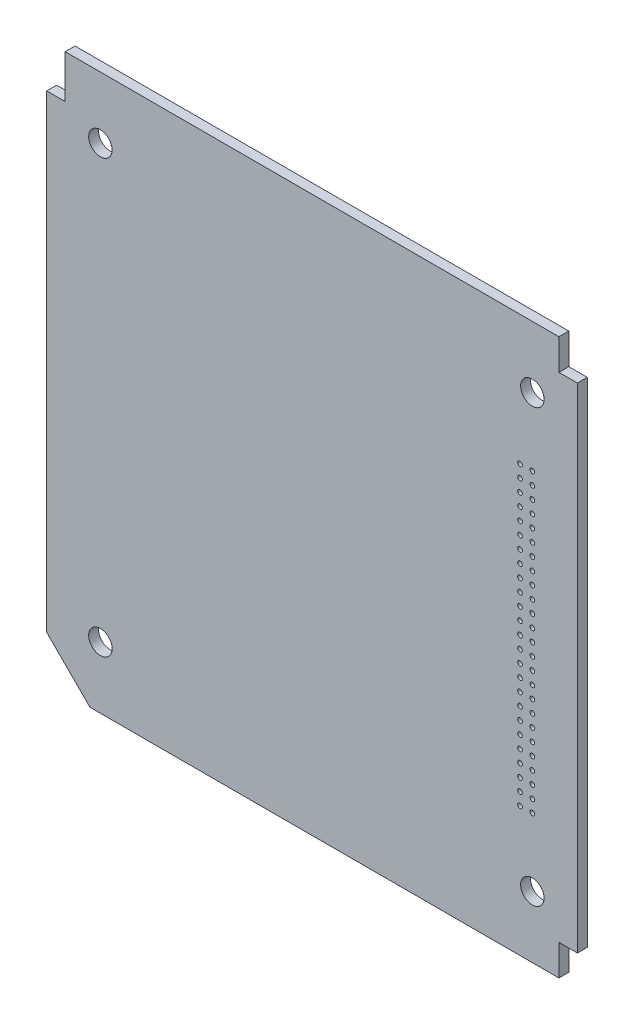
from build123d import *

# Parameters (mm, degrees)
SKETCH1_R           = 1.9
SKETCH1_R_2         = 0.375
SKETCH1_R_3         = 0.383755901
SKETCH1_R_4         = 0.384163196
SKETCH1_R_5         = 0.380771211
SKETCH1_R_6         = 0.377379225
SKETCH1_R_7         = 0.380832793
BOSS_EXTRUDE1_DEPTH = 1.6
SKETCH_1_W          = 3
SKETCH_1_H          = 7
CUT_EXTRUDE_1_DEPTH = 10


with BuildPart() as part:
    # Sketch1 → Boss-Extrude1 (new body)
    with BuildSketch(Plane.XY):
        Polygon((-3, 0), (-86, 0), (-86, -90), (-3, -90), (-3, -85), (0, -85), (0, -5), (-3, -5), align=None)
        with Locations((-7.3, -10)):
            Circle(SKETCH1_R, mode=Mode.SUBTRACT)
        with Locations((-77.3, -10)):
            Circle(SKETCH1_R, mode=Mode.SUBTRACT)
        with Locations((-77.3, -80)):
            Circle(SKETCH1_R, mode=Mode.SUBTRACT)
        with Locations((-7.3, -80)):
            Circle(SKETCH1_R, mode=Mode.SUBTRACT)
        with Locations((-9.3, -69)):
            Circle(SKETCH1_R_2, mode=Mode.SUBTRACT)
        with Locations((-7.3, -69)):
            Circle(SKETCH1_R_2, mode=Mode.SUBTRACT)
        with Locations((-7.3, -67)):
            Circle(SKETCH1_R_2, mode=Mode.SUBTRACT)
        with Locations((-9.3, -67)):
            Circle(SKETCH1_R_2, mode=Mode.SUBTRACT)
        with Locations((-9.3, -65)):
            Circle(SKETCH1_R_2, mode=Mode.SUBTRACT)
        with Locations((-7.3, -65)):
            Circle(SKETCH1_R_2, mode=Mode.SUBTRACT)
        with Locations((-7.3, -63)):
            Circle(SKETCH1_R_2, mode=Mode.SUBTRACT)
        with Locations((-9.3, -63)):
            Circle(SKETCH1_R_3, mode=Mode.SUBTRACT)
        with Locations((-9.3, -61)):
            Circle(SKETCH1_R_2, mode=Mode.SUBTRACT)
        with Locations((-7.3, -61)):
            Circle(SKETCH1_R_2, mode=Mode.SUBTRACT)
        with Locations((-7.3, -59)):
            Circle(SKETCH1_R_2, mode=Mode.SUBTRACT)
        with Locations((-9.3, -59)):
            Circle(SKETCH1_R_2, mode=Mode.SUBTRACT)
        with Locations((-7.3, -57)):
            Circle(SKETCH1_R_2, mode=Mode.SUBTRACT)
        with Locations((-9.3, -57)):
            Circle(SKETCH1_R_2, mode=Mode.SUBTRACT)
        with Locations((-9.3, -55)):
            Circle(SKETCH1_R_2, mode=Mode.SUBTRACT)
        with Locations((-7.3, -55)):
            Circle(SKETCH1_R_2, mode=Mode.SUBTRACT)
        with Locations((-7.3, -53)):
            Circle(SKETCH1_R_2, mode=Mode.SUBTRACT)
        with Locations((-9.3, -53)):
            Circle(SKETCH1_R_2, mode=Mode.SUBTRACT)
        with Locations((-9.3, -51)):
            Circle(SKETCH1_R_2, mode=Mode.SUBTRACT)
        with Locations((-7.3, -51)):
            Circle(SKETCH1_R_2, mode=Mode.SUBTRACT)
        with Locations((-7.3, -49)):
            Circle(SKETCH1_R_2, mode=Mode.SUBTRACT)
        with Locations((-9.3, -49)):
            Circle(SKETCH1_R_2, mode=Mode.SUBTRACT)
        with Locations((-9.3, -47)):
            Circle(SKETCH1_R_2, mode=Mode.SUBTRACT)
        with Locations((-7.3, -47)):
            Circle(SKETCH1_R_2, mode=Mode.SUBTRACT)
        with Locations((-7.3, -45)):
            Circle(SKETCH1_R_2, mode=Mode.SUBTRACT)
        with Locations((-9.3, -45)):
            Circle(SKETCH1_R_4, mode=Mode.SUBTRACT)
        with Locations((-9.3, -43)):
            Circle(SKETCH1_R_2, mode=Mode.SUBTRACT)
        with Locations((-7.3, -43)):
            Circle(SKETCH1_R_5, mode=Mode.SUBTRACT)
        with Locations((-7.3, -41)):
            Circle(SKETCH1_R_6, mode=Mode.SUBTRACT)
        with Locations((-9.3, -41)):
            Circle(SKETCH1_R_6, mode=Mode.SUBTRACT)
        with Locations((-9.3, -39)):
            Circle(SKETCH1_R_2, mode=Mode.SUBTRACT)
        with Locations((-7.3, -39)):
            Circle(SKETCH1_R_2, mode=Mode.SUBTRACT)
        with Locations((-7.3, -37)):
            Circle(SKETCH1_R_2, mode=Mode.SUBTRACT)
        with Locations((-9.3, -37)):
            Circle(SKETCH1_R_7, mode=Mode.SUBTRACT)
        with Locations((-7.3, -35)):
            Circle(SKETCH1_R_2, mode=Mode.SUBTRACT)
        with Locations((-9.3, -35)):
            Circle(SKETCH1_R_2, mode=Mode.SUBTRACT)
        with Locations((-9.3, -33)):
            Circle(SKETCH1_R_2, mode=Mode.SUBTRACT)
        with Locations((-7.3, -33)):
            Circle(SKETCH1_R_2, mode=Mode.SUBTRACT)
        with Locations((-7.3, -31)):
            Circle(SKETCH1_R_2, mode=Mode.SUBTRACT)
        with Locations((-9.3, -31)):
            Circle(SKETCH1_R_2, mode=Mode.SUBTRACT)
        with Locations((-7.3, -29)):
            Circle(SKETCH1_R_2, mode=Mode.SUBTRACT)
        with Locations((-9.3, -29)):
            Circle(SKETCH1_R_2, mode=Mode.SUBTRACT)
        with Locations((-9.3, -27)):
            Circle(SKETCH1_R_2, mode=Mode.SUBTRACT)
        with Locations((-7.3, -27)):
            Circle(SKETCH1_R_2, mode=Mode.SUBTRACT)
        with Locations((-7.3, -25)):
            Circle(SKETCH1_R_2, mode=Mode.SUBTRACT)
        with Locations((-9.3, -25)):
            Circle(SKETCH1_R_2, mode=Mode.SUBTRACT)
        with Locations((-7.3, -23)):
            Circle(SKETCH1_R_2, mode=Mode.SUBTRACT)
        with Locations((-9.3, -23)):
            Circle(SKETCH1_R_2, mode=Mode.SUBTRACT)
        with Locations((-9.3, -21)):
            Circle(SKETCH1_R_2, mode=Mode.SUBTRACT)
        with Locations((-7.3, -21)):
            Circle(SKETCH1_R_2, mode=Mode.SUBTRACT)
    extrude(amount=BOSS_EXTRUDE1_DEPTH)

    # ｽｹｯﾁ1 → ｶｯﾄ - 押し出し1 (cut)
    with BuildSketch(Plane.XY.offset(1.6)):
        Polygon((-86, -90), (-86, -83), (-79, -90), align=None)
        with Locations((-84.5, -3.5)):
            Rectangle(SKETCH_1_W, SKETCH_1_H)
    extrude(amount=-CUT_EXTRUDE_1_DEPTH, mode=Mode.SUBTRACT)


solid = part.part
